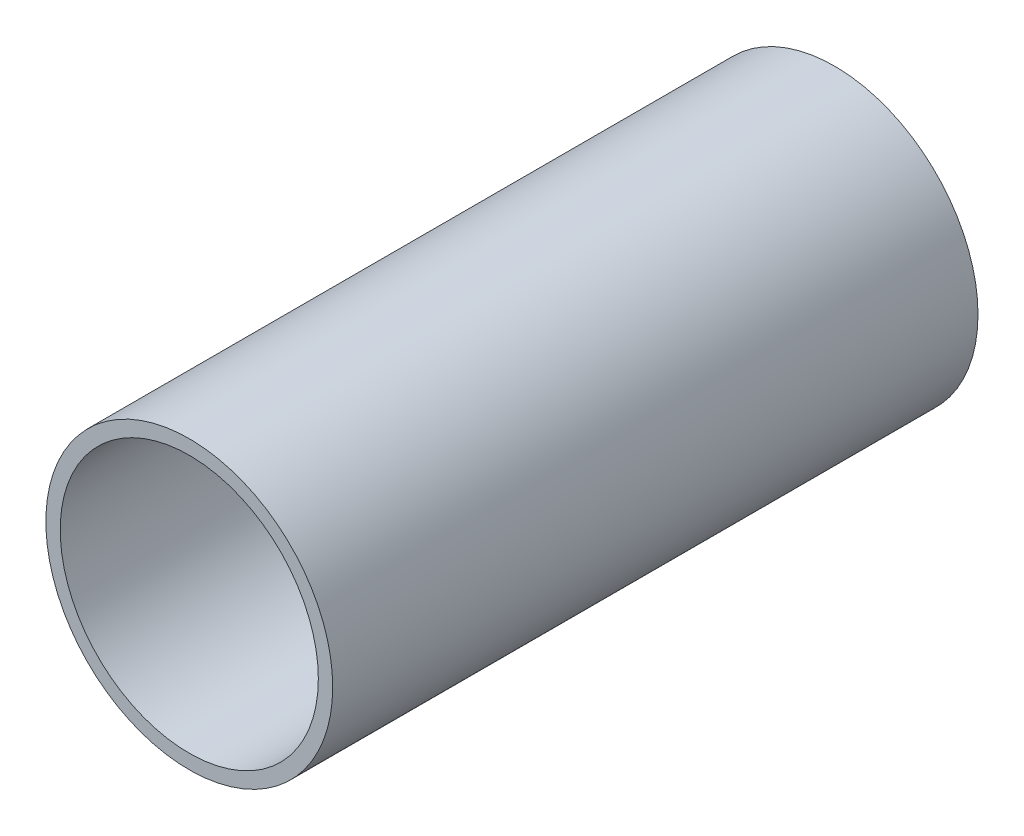
from build123d import *

# Parameters (mm, degrees)
SKETCH1_R           = 22.225
SKETCH1_R_2         = 20
BOSS_EXTRUDE1_DEPTH = 100


with BuildPart() as part:
    # Sketch1 → Boss-Extrude1 (new body)
    with BuildSketch(Plane.XY):
        Circle(SKETCH1_R)
        Circle(SKETCH1_R_2, mode=Mode.SUBTRACT)
    extrude(amount=BOSS_EXTRUDE1_DEPTH)


solid = part.part
